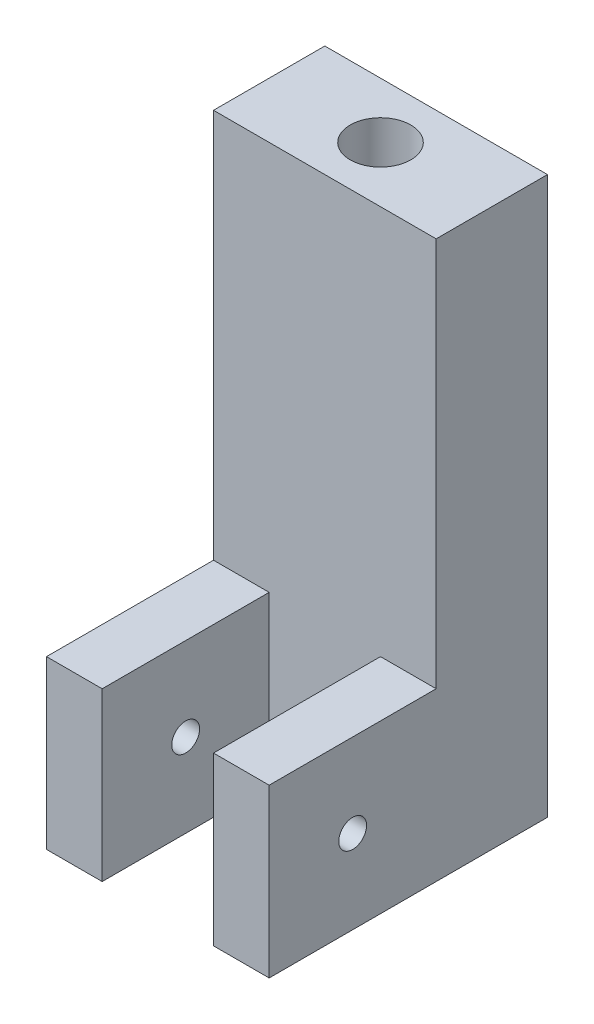
from build123d import *

# Parameters (mm, degrees)
BOSS_EXTRUDE1_DEPTH      = 25.4
SKETCH2_R                = 1.5875
CUT_EXTRUDE1_DEPTH       = 26.4
SKETCH3_W                = 12.7
SKETCH3_H                = 19.05
CUT_EXTRUDE2_DEPTH       = 19.05
F_5_16_24_TAPPED_HOLE1_D = 6.9088


with BuildPart() as part:
    # Sketch1 → Boss-Extrude1 (new body)
    with BuildSketch(Plane(origin=(0, 0, 0), x_dir=(0, 0, -1), z_dir=(1, 0, 0))):
        Polygon((0, 0), (0, 63.5), (-12.7, 63.5), (-12.7, 19.05), (-31.75, 19.05), (-31.75, 0), align=None)
    extrude(amount=BOSS_EXTRUDE1_DEPTH)

    # Sketch2 → Cut-Extrude1 (cut, through all)
    with BuildSketch(Plane(origin=(25.4, 0, 0), x_dir=(0, 0, -1), z_dir=(1, 0, 0))):
        with Locations((-22.225, 9.525)):
            Circle(SKETCH2_R)
    extrude(amount=-CUT_EXTRUDE1_DEPTH, mode=Mode.SUBTRACT)

    # Sketch3 → Cut-Extrude2 (cut)
    with BuildSketch(Plane.XY.offset(31.75)):
        with Locations((12.7, 9.525)):
            Rectangle(SKETCH3_W, SKETCH3_H)
    extrude(amount=-CUT_EXTRUDE2_DEPTH, mode=Mode.SUBTRACT)

    # 5/16-24 Tapped Hole1 (through all)
    with Locations(Plane(origin=(0, 63.5, 0), x_dir=(1, 0, 0), z_dir=(0, 1, 0))):
        with Locations((12.7, -6.35)):
            Hole(F_5_16_24_TAPPED_HOLE1_D / 2)


solid = part.part
